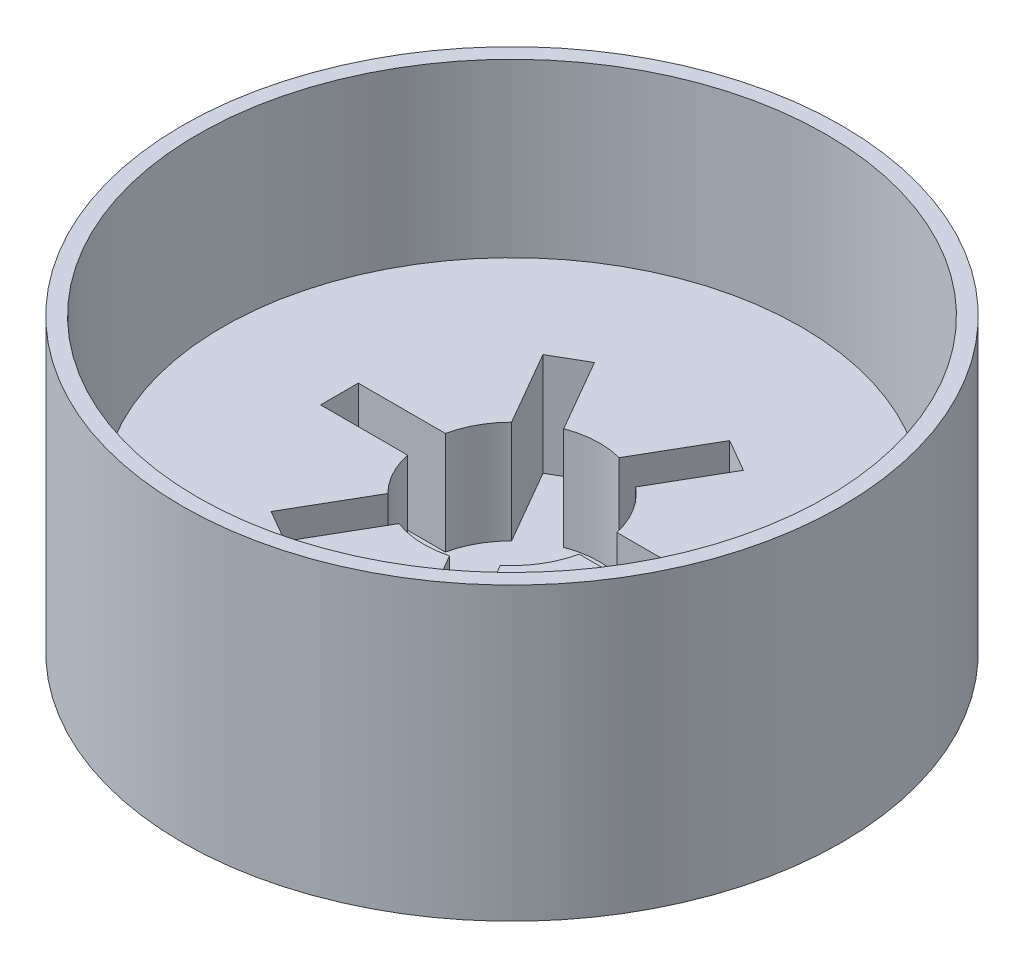
from build123d import *

# Parameters (mm, degrees)
SKETCH3_R           = 48.895
BOSS_EXTRUDE2_DEPTH = 5.08
SKETCH4_R           = 42.9006
BOSS_EXTRUDE3_DEPTH = 15.24
SKETCH5_R           = 48.895
SKETCH5_R_2         = 46.609
BOSS_EXTRUDE4_DEPTH = 38.1
CUT_EXTRUDE1_DEPTH  = 0.2


with BuildPart() as part:
    # Sketch3 → Boss-Extrude2 (new body)
    with BuildSketch(Plane(origin=(0, 0, 0), x_dir=(1, 0, 0), z_dir=(0, 1, 0))):
        with Locations(Location((0, 0, 0), (0, 0, 270))):  # turned: the seam where the file's is
            Circle(SKETCH3_R)
    extrude(amount=BOSS_EXTRUDE2_DEPTH)

    # Sketch4 → Boss-Extrude3 (add)
    with BuildSketch(Plane(origin=(0, 5.08, 0), x_dir=(1, 0, 0), z_dir=(0, 1, 0))):
        with Locations(Location((0, 0, 0), (0, 0, 270))):  # turned: the seam where the file's is
            Circle(SKETCH4_R)
        with BuildLine():
            ThreePointArc((-4.567935909, -12.199290546), (-0.649198876, -13.01027552), (3.330805622, -12.593429326))
            Line((3.330805622, -12.593429326), (9.293981813, -22.921953464))
            Line((9.293981813, -22.921953464), (14.133331769, -20.127953464))
            Line((14.133331769, -20.127953464), (8.306068354, -10.034837158))
            ThreePointArc((8.306068354, -10.034837158), (11.129081005, -6.769954526), (12.730314912, -2.761849113))
            Line((12.730314912, -2.761849113), (24.159656791, -2.761849113))
            Line((24.159656791, -2.761849113), (24.159656791, 2.826150887))
            Line((24.159656791, 2.826150887), (12.716194378, 2.826150887))
            ThreePointArc((12.716194378, 2.826150887), (11.103422614, 6.811955266), (8.280927567, 10.055593813))
            Line((8.280927567, 10.055593813), (14.133331769, 20.192255238))
            Line((14.133331769, 20.192255238), (9.293981813, 22.986255238))
            Line((9.293981813, 22.986255238), (3.298576906, 12.601909327))
            ThreePointArc((3.298576906, 12.601909327), (-0.649560207, 13.010257485), (-4.537389725, 12.210684779))
            Line((-4.537389725, 12.210684779), (-10.758668231, 22.986255238))
            Line((-10.758668231, 22.986255238), (-15.598018187, 20.192255238))
            Line((-15.598018187, 20.192255238), (-9.240826906, 9.181276947))
            ThreePointArc((-9.240826906, 9.181276947), (-11.429112071, 6.250130044), (-12.716194378, 2.826150887))
            Line((-12.716194378, 2.826150887), (-25.624343209, 2.826150887))
            Line((-25.624343209, 2.826150887), (-25.624343209, -2.761849113))
            Line((-25.624343209, -2.761849113), (-12.730314912, -2.761849113))
            ThreePointArc((-12.730314912, -2.761849113), (-11.452817768, -6.206584686), (-9.26428516, -9.15760606))
            Line((-9.26428516, -9.15760606), (-15.598018187, -20.127953464))
            Line((-15.598018187, -20.127953464), (-10.758668231, -22.921953464))
            Line((-10.758668231, -22.921953464), (-4.567935909, -12.199290546))
        make_face(mode=Mode.SUBTRACT)
    extrude(amount=BOSS_EXTRUDE3_DEPTH)

    # Sketch5 → Boss-Extrude4 (add)
    with BuildSketch(Plane(origin=(0, 5.08, 0), x_dir=(1, 0, 0), z_dir=(0, 1, 0))):
        with Locations(Location((0, 0, 0), (0, 0, 270))):  # turned: the seam where the file's is
            Circle(SKETCH5_R)
        with Locations(Location((0, 0, 0), (0, 0, 270))):  # turned: the seam where the file's is
            Circle(SKETCH5_R_2, mode=Mode.SUBTRACT)
    extrude(amount=BOSS_EXTRUDE4_DEPTH)

    # Sketch7 → Cut-Extrude1 (cut)
    with BuildSketch(Plane.XZ):
        with BuildLine():
            Line((10.189077573, 28.777139206), (3.905470201, 28.777139206))
            add(Edge.make_bspline(
                [(3.905470201, 28.777139206), (5.673403675, 10.082176027), (2.072299934, -8.408708001)],
                knots=[0, 0, 0, 1, 1, 1], degree=2))
            Line((2.072299934, -8.408708001), (1.578207561, -8.290715793))
            Line((1.578207561, -8.290715793), (0.93540787, -10.43338143))
            add(Edge.make_bspline(
                [(0.93540787, -10.43338143), (-1.730658467, -9.24791296), (-2.648379288, -6.465006437)],
                knots=[0, 0, 0, 1, 1, 1], degree=2))
            add(Edge.make_bspline(
                [(-1.535058391, -14.046142711), (-3.997790421, -10.512351861), (-2.648379288, -6.465006437)],
                knots=[0, 0, 0, 1, 1, 1], degree=2))
            add(Edge.make_bspline(
                [(-5.496336768, -32.152202336), (-5.134044818, -22.716243693), (-1.535058391, -14.046142711)],
                knots=[0, 0, 0, 1, 1, 1], degree=2))
            add(Edge.make_bspline(
                [(-3.921713234, -32.261214734), (-5.591404908, -34.721729292), (-5.496336768, -32.152202336)],
                knots=[0, 0, 0, 1, 1, 1], degree=2))
            add(Edge.make_bspline(
                [(-3.921713234, -32.261214734), (0.67700242, -24.157422119), (3.257772607, -15.187585129)],
                knots=[0, 0, 0, 1, 1, 1], degree=2))
            add(Edge.make_bspline(
                [(3.257772607, -15.187585129), (7.244573316, -13.614377412), (9.294943691, -9.762880676)],
                knots=[0, 0, 0, 1, 1, 1], degree=2))
            add(Edge.make_bspline(
                [(3.445088013, -11.186285473), (6.51327774, -11.392596023), (9.294943691, -9.762880676)],
                knots=[0, 0, 0, 1, 1, 1], degree=2))
            Line((3.445088013, -11.186285473), (4.130880832, -8.90030941))
            Line((4.130880832, -8.90030941), (3.845040397, -8.832049008))
            add(Edge.make_bspline(
                [(10.189077573, 28.777139206), (10.494453194, 9.291070289), (3.845040397, -8.832049008)],
                knots=[0, 0, 0, 1, 1, 1], degree=2))
        make_face()
    extrude(amount=-CUT_EXTRUDE1_DEPTH, mode=Mode.SUBTRACT)


solid = part.part
